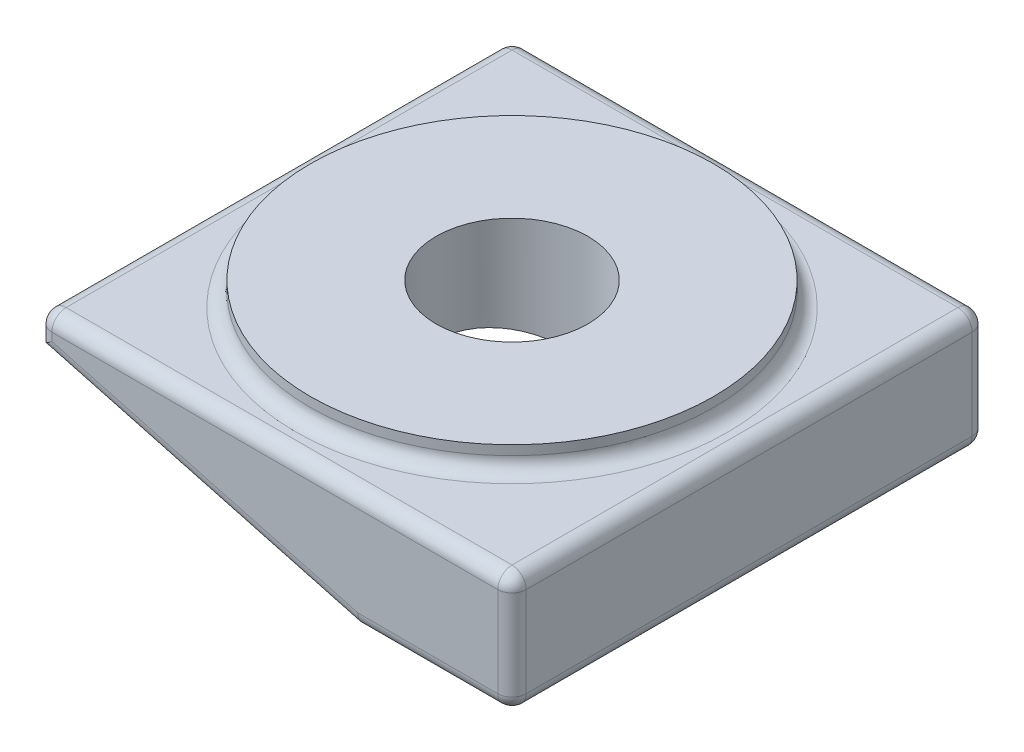
from build123d import *

# Parameters (mm, degrees)
BOSS_EXTRUDE1_DEPTH = 50
SKETCH3_R           = 42.5
SKETCH3_R_2         = 16
BOSS_EXTRUDE2_DEPTH = 5
SKETCH4_R           = 16
CUT_EXTRUDE1_DEPTH  = 26
SKETCH6_W           = 100.044775272
SKETCH6_H           = 92
CUT_EXTRUDE3_DEPTH  = 2
FILLET1_R           = 3


with BuildPart() as part:
    # Sketch2 → Boss-Extrude1 (new body, symmetric)
    with BuildSketch(Plane.XY):
        Polygon((0, 0), (0, 25), (-100, 25), (-100, 18), (-32.823085464, 0), align=None)
    extrude(amount=BOSS_EXTRUDE1_DEPTH, both=True)

    # Sketch3 → Boss-Extrude2 (add)
    with BuildSketch(Plane(origin=(0, 25, 0), x_dir=(1, 0, 0), z_dir=(0, 1, 0))):
        with Locations((-50, 0)):
            Circle(SKETCH3_R)
        with Locations((-50, 0)):
            Circle(SKETCH3_R_2, mode=Mode.SUBTRACT)
    extrude(amount=BOSS_EXTRUDE2_DEPTH)

    # Sketch4 → Cut-Extrude1 (cut, through all)
    with BuildSketch(Plane(origin=(0, 25, 0), x_dir=(1, 0, 0), z_dir=(0, 1, 0))):
        with Locations((-50, 0)):
            Circle(SKETCH4_R)
    extrude(amount=-CUT_EXTRUDE1_DEPTH, mode=Mode.SUBTRACT)

    # Sketch6 → Cut-Extrude3 (cut)
    with BuildSketch(Plane(origin=(-2.198729811, -8.205771366, 0), x_dir=(0.965925826, -0.258819045, 0), z_dir=(-0.258819045, -0.965925826, 0))):
        with Locations((-62.936330428, 0)):
            Rectangle(SKETCH6_W, SKETCH6_H)
    extrude(amount=-CUT_EXTRUDE3_DEPTH, mode=Mode.SUBTRACT)

    # Fillet1
    fillet1_edges = [part.edges().sort_by_distance(p)[0] for p in [
        (-50, 25, 50),
        (-100, 21.5, 50),
        (-92.5, 25, 0),
        (-66.411542732, 9, 50),
        (-16.411542732, 0, 50),
        (-66.411542732, 9, -50),
        (-100, 21.5, -50),
        (-50, 25, -50),
        (0, 12.5, -50),
        (-16.411542732, 0, -50),
        (0, 12.5, 50),
        (-100, 25, 0),
        (0, 25, 0),
        (0, 0, 0),
    ]]
    fillet(fillet1_edges, radius=FILLET1_R)


solid = part.part
